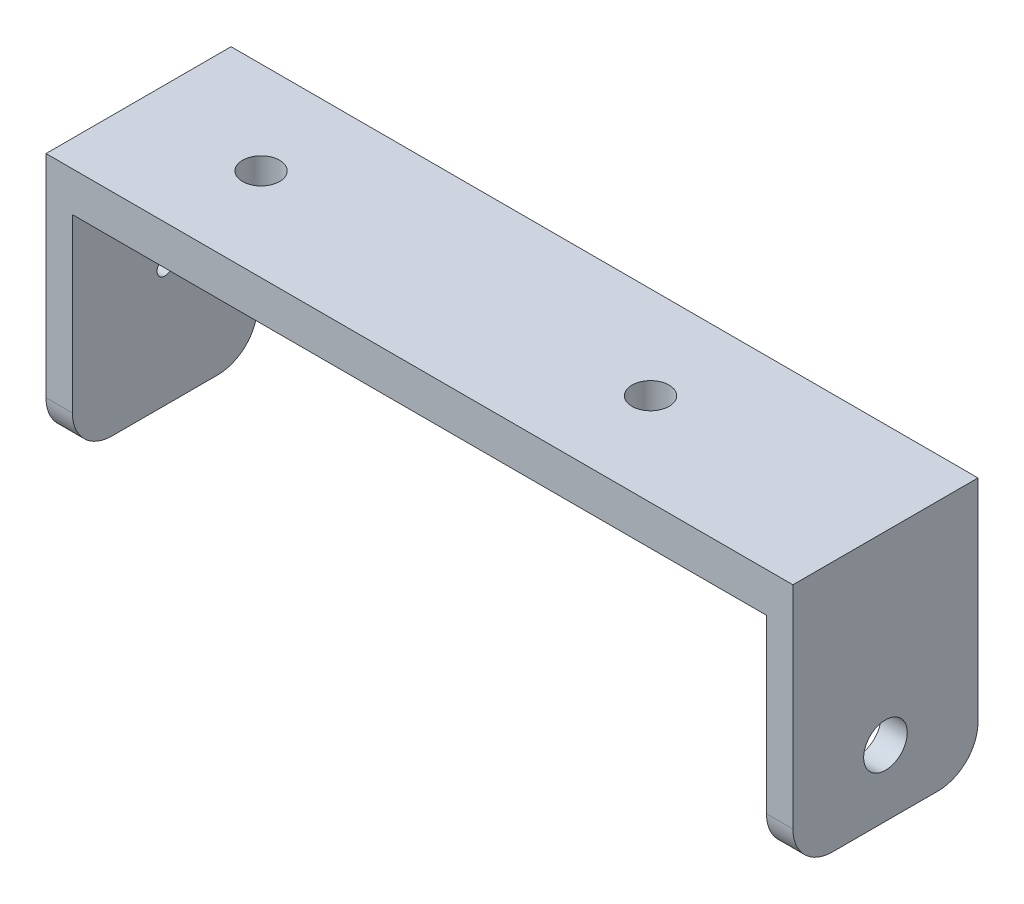
from build123d import *

# Parameters (mm, degrees)
EXTRUDE_1_DEPTH     = 14
SKETCH_2_R          = 1.65
CUT_EXTRUDE_1_DEPTH = 2
SKETCH_3_R          = 1.4
CUT_EXTRUDE_2_DEPTH = 14
FILLET_1_R          = 3
SKETCH_5_R          = 0.6
CUT_EXTRUDE_3_DEPTH = 10


with BuildPart() as part:
    # 草图1 → 凸台-拉伸1 (new body)
    with BuildSketch(Plane.XY):
        Polygon((-28.25, 0), (-28.25, 19), (28.25, 19), (28.25, 0), (26.25, 0), (26.25, 16), (-26.25, 16), (-26.25, 0), align=None)
    extrude(amount=EXTRUDE_1_DEPTH)

    # 草图2 → 切除-拉伸1 (cut)
    with BuildSketch(Plane(origin=(28.25, 0, 0), x_dir=(0, 0, -1), z_dir=(1, 0, 0))):
        with Locations((-7, 5)):
            Circle(SKETCH_2_R)
    extrude(amount=-CUT_EXTRUDE_1_DEPTH, mode=Mode.SUBTRACT)

    # 草图3 → 切除-拉伸2 (cut)
    with BuildSketch(Plane(origin=(0, 19, 0), x_dir=(1, 0, 0), z_dir=(0, 1, 0))):
        with Locations((-18.98, -7)):
            Circle(SKETCH_3_R)
        with Locations((10.48, -7)):
            Circle(SKETCH_3_R)
    extrude(amount=-CUT_EXTRUDE_2_DEPTH, mode=Mode.SUBTRACT)

    # 圆角1
    fillet_1_edges = [part.edges().sort_by_distance(p)[0] for p in [
        (-27.25, 0, 0),
        (27.25, 0, 0),
        (27.25, 0, 14),
        (-27.25, 0, 14),
    ]]
    fillet(fillet_1_edges, radius=FILLET_1_R)

    # 草图5 → 切除-拉伸3 (cut)
    with BuildSketch(Plane.ZY.offset(28.25)):
        with Locations((7, 9.085)):
            Circle(SKETCH_5_R)
        with Locations((7, 13.085)):
            Circle(SKETCH_5_R)
    extrude(amount=-CUT_EXTRUDE_3_DEPTH, mode=Mode.SUBTRACT)


solid = part.part
